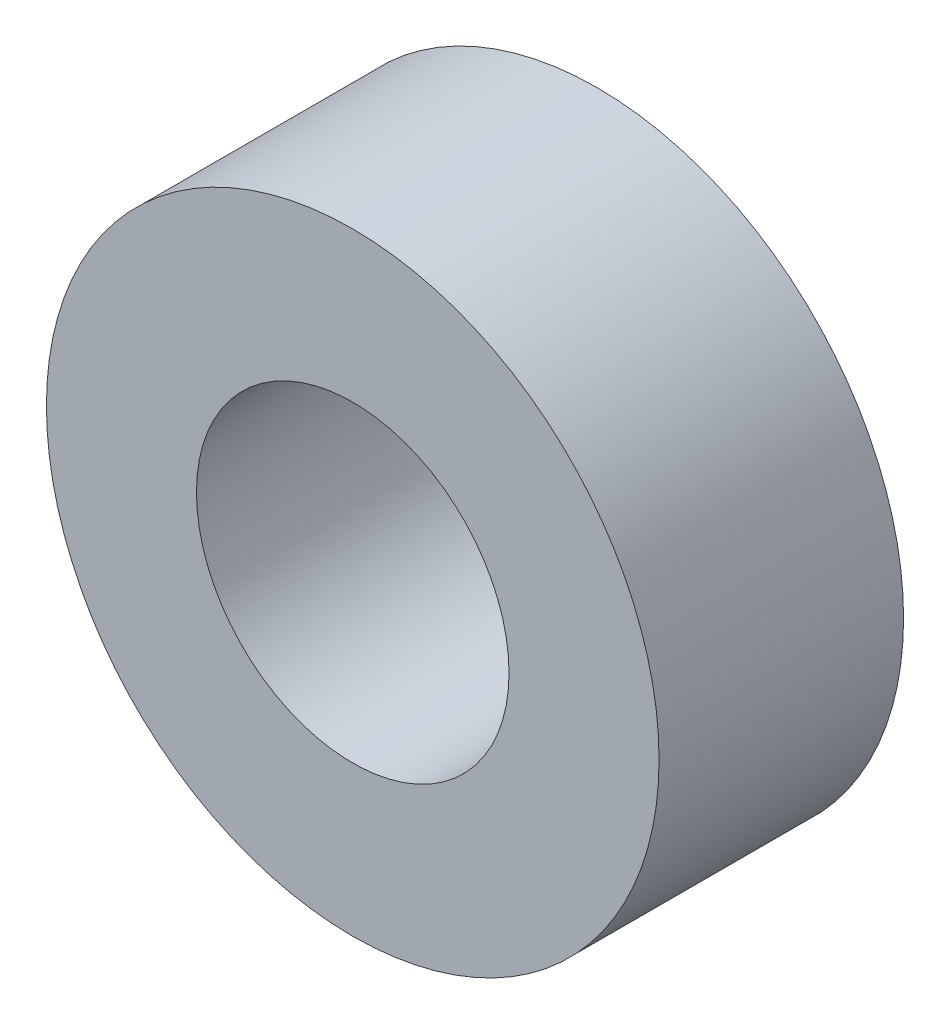
from build123d import *

# Parameters (mm, degrees)
SKETCH1_R           = 18.669
SKETCH1_R_2         = 9.525
BOSS_EXTRUDE1_DEPTH = 7.450808568


with BuildPart() as part:
    # Sketch1 → Boss-Extrude1 (new body, symmetric)
    with BuildSketch(Plane.XY):
        Circle(SKETCH1_R)
        Circle(SKETCH1_R_2, mode=Mode.SUBTRACT)
    extrude(amount=BOSS_EXTRUDE1_DEPTH, both=True)


solid = part.part
